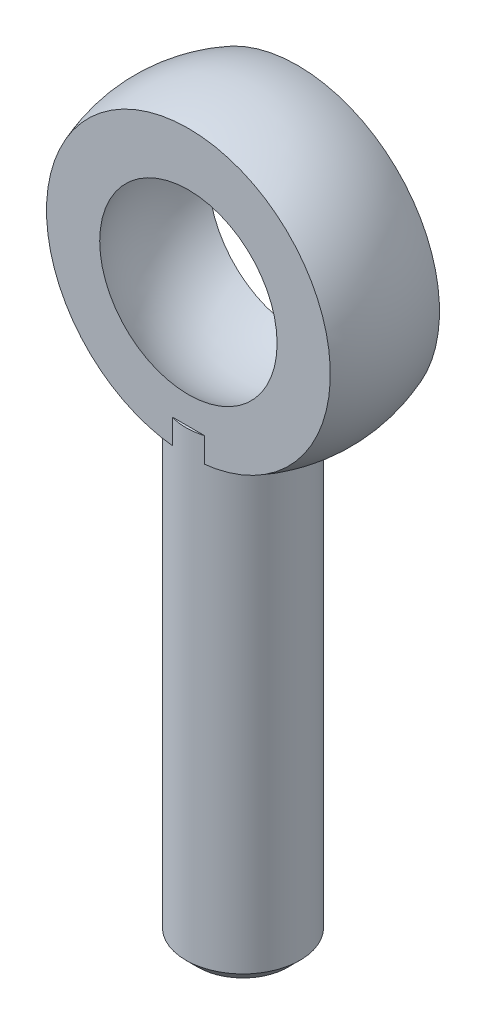
from build123d import *

# Parameters (mm, degrees)
SKETCH5_R           = 4.7625
EXTRUDE2_DEPTH      = 3
EXTRUDE2_DEPTH_BACK = 36.53
CHAMFER1_SIZE       = 1


with BuildPart() as part:
    # Sketch3 → Revolve2 (revolve)
    with BuildSketch(Plane(origin=(0, 0, 0), x_dir=(0, 0, -1), z_dir=(1, 0, 0))):
        with BuildLine():
            Line((-4.56, 11.853117733), (-4.56, 0))
            Line((-4.56, 0), (4.56, 0))
            Line((4.56, 0), (4.56, 11.853117733))
            ThreePointArc((4.56, 11.853117733), (0, 12.7), (-4.56, 11.853117733))
        make_face()
    revolve(axis=Axis((0, 0, 8.146649187), (0, 0, -1)))

    # Sketch2 → Cut-Revolve2 (revolve, cut)
    with BuildSketch(Plane(origin=(0, 0, 0), x_dir=(0, 0, -1), z_dir=(1, 0, 0))):
        with BuildLine():
            Line((0, 8.7), (0, -8.7))
            ThreePointArc((0, -8.7), (8.7, 0), (0, 8.7))
        make_face()
    revolve(axis=Axis((0, 15.474361319, 0), (0, -1, 0)), mode=Mode.SUBTRACT)


with BuildPart() as body_2:
    # Sketch5 → Extrude2 (new body, two sides)
    with BuildSketch(Plane(origin=(0, -12.7, 0), x_dir=(-1, 0, 0), z_dir=(0, 1, 0))) as extrude2_sk:
        Circle(SKETCH5_R)
    extrude(amount=EXTRUDE2_DEPTH)
    extrude(extrude2_sk.sketch, amount=-EXTRUDE2_DEPTH_BACK)

    # Chamfer1
    chamfer1_edges = [body_2.edges().sort_by_distance(p)[0] for p in [
        (4.7625, -49.23, 0),
    ]]
    chamfer(chamfer1_edges, length=CHAMFER1_SIZE)


solid = Compound([part.part, body_2.part])
